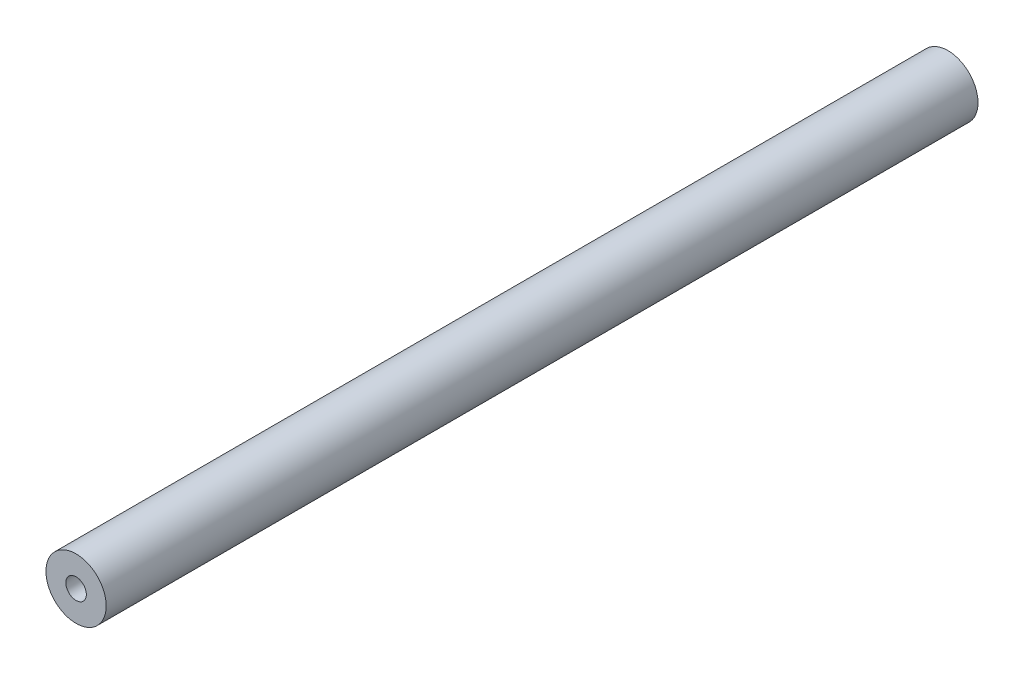
from build123d import *

# Parameters (mm, degrees)
SKETCH_1_R                        = 15
EXTRUDE_1_DEPTH                   = 217
HOLE_WIZARD_M12_1_D               = 10.2
HOLE_WIZARD_M12_1_DEPTH           = 29.25
HOLE_WIZARD_M12_1_TIP             = 3.064389157
HOLE_WIZARD_M12_1_ON_FACE_2_D     = 10.2
HOLE_WIZARD_M12_1_ON_FACE_2_DEPTH = 29.25
HOLE_WIZARD_M12_1_ON_FACE_2_TIP   = 3.064389157


with BuildPart() as part:
    # 草图1 → 凸台-拉伸1 (new body, symmetric)
    with BuildSketch(Plane.XY):
        Circle(SKETCH_1_R)
    extrude(amount=EXTRUDE_1_DEPTH, both=True)

    # M12 螺纹孔1
    with Locations(Plane.XY.offset(217)):
        with Locations((0, 0)):
            Hole(HOLE_WIZARD_M12_1_D / 2, depth=HOLE_WIZARD_M12_1_DEPTH)
            with Locations((0, 0, -(HOLE_WIZARD_M12_1_DEPTH + HOLE_WIZARD_M12_1_TIP / 2))):  # 118° drill point
                Cone(0, HOLE_WIZARD_M12_1_D / 2, HOLE_WIZARD_M12_1_TIP, mode=Mode.SUBTRACT)

    # M12 螺纹孔1 on face 2
    with Locations(Plane(origin=(0, 0, -217), x_dir=(-1, 0, 0), z_dir=(0, 0, -1))):
        with Locations((0, 0)):
            Hole(HOLE_WIZARD_M12_1_ON_FACE_2_D / 2, depth=HOLE_WIZARD_M12_1_ON_FACE_2_DEPTH)
            with Locations((0, 0, -(HOLE_WIZARD_M12_1_ON_FACE_2_DEPTH + HOLE_WIZARD_M12_1_ON_FACE_2_TIP / 2))):  # 118° drill point
                Cone(0, HOLE_WIZARD_M12_1_ON_FACE_2_D / 2, HOLE_WIZARD_M12_1_ON_FACE_2_TIP, mode=Mode.SUBTRACT)


solid = part.part
